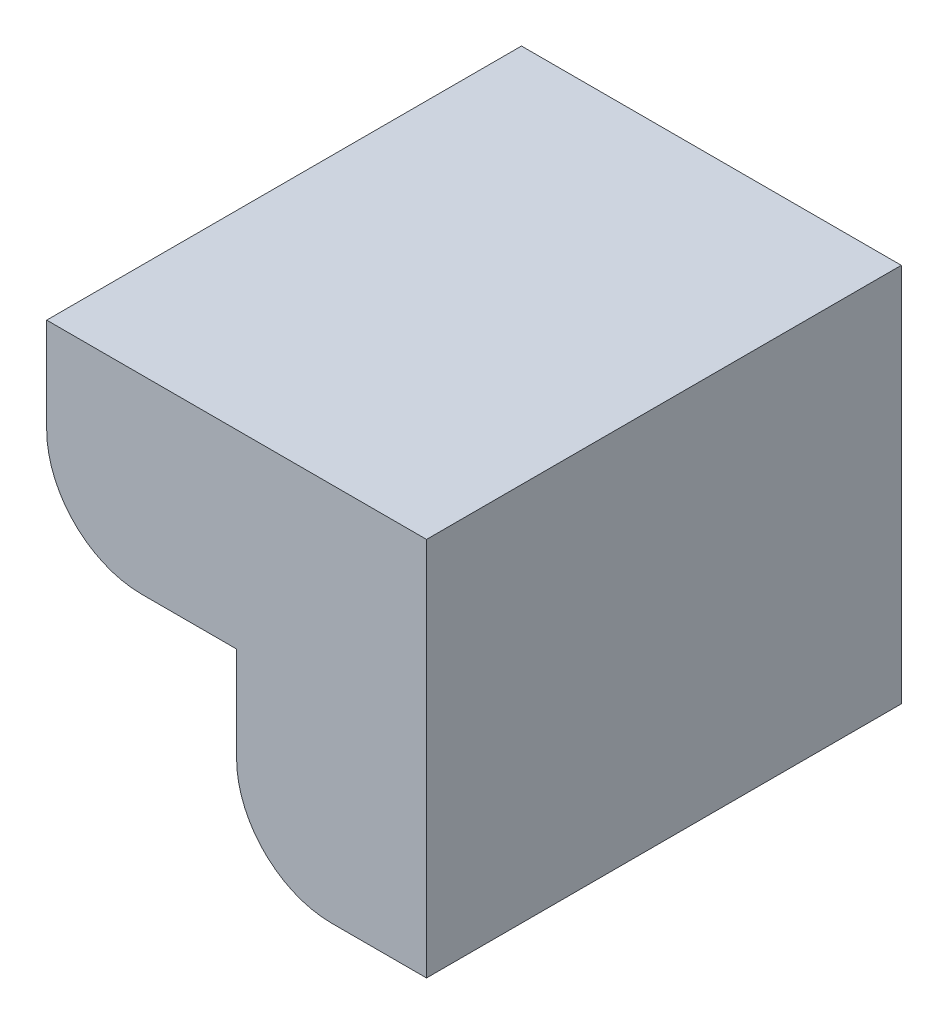
from build123d import *

# Parameters (mm, degrees)
BOSS_EXTRUDE1_DEPTH = 25


with BuildPart() as part:
    # Sketch1 → Boss-Extrude1 (new body)
    with BuildSketch(Plane.XY):
        with BuildLine():
            Line((-10, 10), (10, 10))
            Line((10, 10), (10, -10))
            Line((10, -10), (5, -10))
            ThreePointArc((5, -10), (1.464466094, -8.535533906), (0, -5))
            Line((0, -5), (0, 0))
            Line((0, 0), (-5, 0))
            ThreePointArc((-5, 0), (-8.535533906, 1.464466094), (-10, 5))
            Line((-10, 5), (-10, 10))
        make_face()
    extrude(amount=BOSS_EXTRUDE1_DEPTH)


solid = part.part
